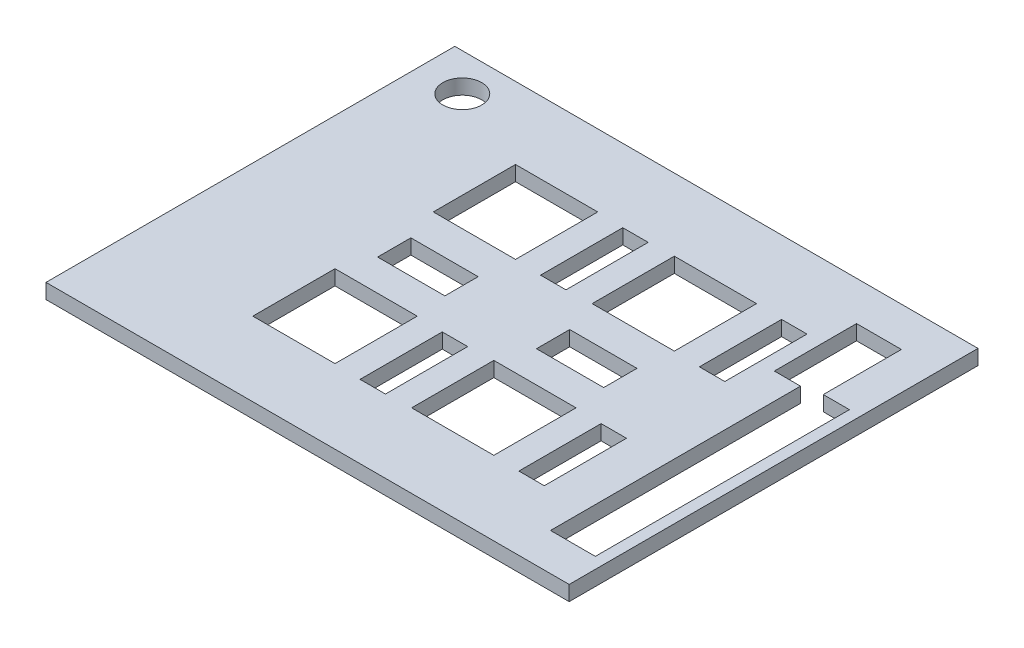
from build123d import *

# Parameters (mm, degrees)
SKETCH2_W           = 70
SKETCH2_H           = 54.7
SKETCH2_W_2         = 11
SKETCH2_H_2         = 11
SKETCH2_W_3         = 3.4
SKETCH2_W_4         = 9
SKETCH2_H_3         = 4.45
SKETCH2_R           = 2.6
BOSS_EXTRUDE1_DEPTH = 2


with BuildPart() as part:
    # Sketch2 → Boss-Extrude1 (new body)
    with BuildSketch(Plane(origin=(0, 0, 0), x_dir=(1, 0, 0), z_dir=(0, 1, 0))):
        with Locations((34, 26.35)):
            Rectangle(SKETCH2_W, SKETCH2_H)
        with Locations((22.25, 14.42)):
            Rectangle(SKETCH2_W_2, SKETCH2_H_2, mode=Mode.SUBTRACT)
        with Locations((32.95, 14.27)):
            Rectangle(SKETCH2_W_3, SKETCH2_H_2, mode=Mode.SUBTRACT)
        Polygon((18.25, 28.57), (22.75, 28.57), (27.25, 28.57), (27.25, 24.12), (22.75, 24.12), (18.25, 24.12), align=None, mode=Mode.SUBTRACT)
        with Locations((43.5, 14.42)):
            Rectangle(SKETCH2_W_2, SKETCH2_H_2, mode=Mode.SUBTRACT)
        with Locations((44, 26.345)):
            Rectangle(SKETCH2_W_4, SKETCH2_H_3, mode=Mode.SUBTRACT)
        with Locations((54.2, 14.27)):
            Rectangle(SKETCH2_W_3, SKETCH2_H_2, mode=Mode.SUBTRACT)
        Polygon((67.5, 4), (61.5, 4), (61.5, 37.45), (58, 37.45), (58, 48.45), (64, 48.45), (64, 38), (67.5, 38), align=None, mode=Mode.SUBTRACT)
        with Locations((22.25, 38.57)):
            Rectangle(SKETCH2_W_2, SKETCH2_H_2, mode=Mode.SUBTRACT)
        with Locations((32.95, 38.42)):
            Rectangle(SKETCH2_W_3, SKETCH2_H_2, mode=Mode.SUBTRACT)
        with Locations((5, 48.7)):
            Circle(SKETCH2_R, mode=Mode.SUBTRACT)
        with Locations((43.5, 38.57)):
            Rectangle(SKETCH2_W_2, SKETCH2_H_2, mode=Mode.SUBTRACT)
        with Locations((54.2, 38.42)):
            Rectangle(SKETCH2_W_3, SKETCH2_H_2, mode=Mode.SUBTRACT)
    extrude(amount=BOSS_EXTRUDE1_DEPTH)


solid = part.part
